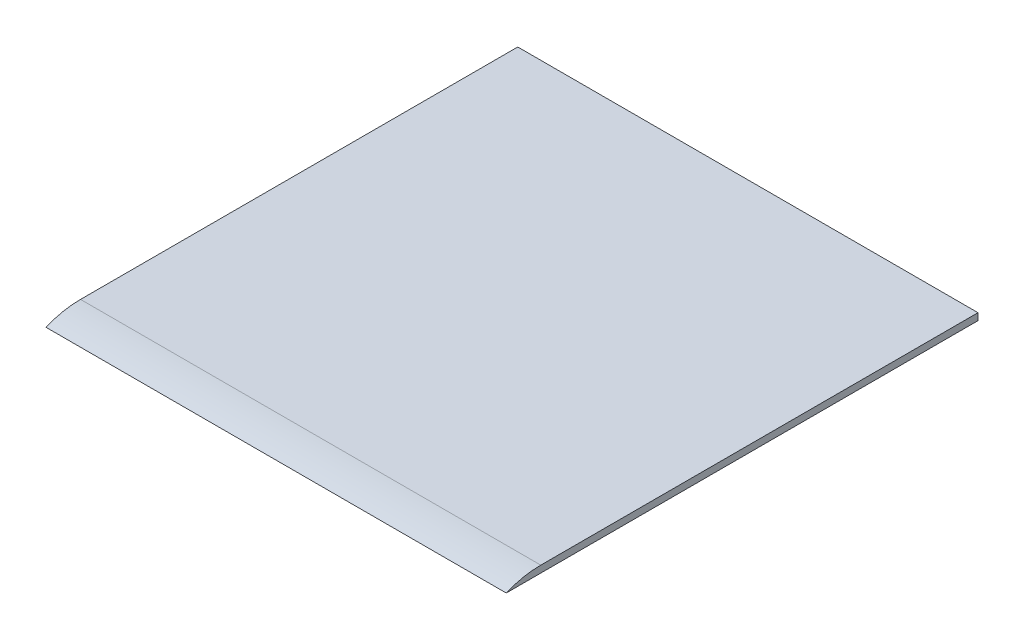
from build123d import *

# Parameters (mm, degrees)
SALIENTE_EXTRUIR1_DEPTH = 100


with BuildPart() as part:
    # Croquis3 → Saliente-Extruir1 (new body, symmetric)
    with BuildSketch(Plane(origin=(0, 0, 0), x_dir=(0, 0, -1), z_dir=(1, 0, 0))):
        with BuildLine():
            Line((102.5, 0), (-102.5, 0))
            ThreePointArc((-102.5, 0), (-95.14852927, 2.242646352), (-87.5, 3))
            Line((-87.5, 3), (102.5, 3))
            Line((102.5, 3), (102.5, 0))
        make_face()
    extrude(amount=SALIENTE_EXTRUIR1_DEPTH, both=True)


solid = part.part
